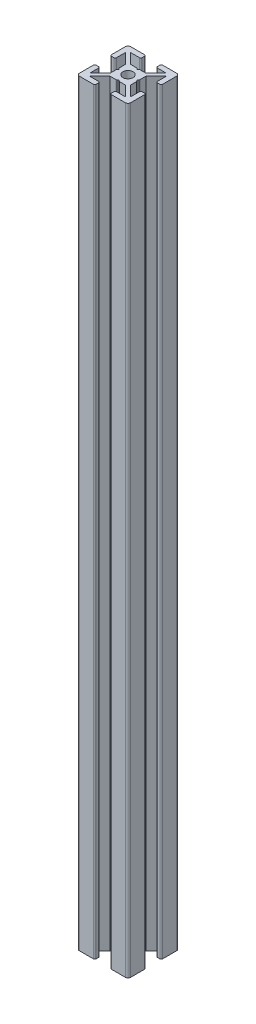
from build123d import *

# Parameters (mm, degrees)
SKETCH1_R           = 2
BOSS_EXTRUDE1_DEPTH = 296
FILLET1_R           = 1
FILLET2_R           = 0.5
FILLET4_R           = 0.5


with BuildPart() as part:
    # Sketch1 → Boss-Extrude1 (new body)
    with BuildSketch(Plane(origin=(0, 0, 0), x_dir=(1, 0, 0), z_dir=(0, 1, 0))):
        Polygon((7, 18), (7, 20), (0, 20), (0, 13), (2, 13), (2, 17), (6, 13), (6, 10.5), (6.5, 10), (6, 9.5), (6, 7), (2, 3), (2, 7), (0, 7), (0, 0), (7, 0), (7, 2), (3, 2), (7, 6), (9.5, 6), (10, 6.5), (10.5, 6), (13, 6), (17, 2), (13, 2), (13, 0), (20, 0), (20, 7), (18, 7), (18, 3), (14, 7), (14, 9.5), (13.5, 10), (14, 10.5), (14, 13), (18, 17), (18, 13), (20, 13), (20, 20), (13, 20), (13, 18), (17, 18), (13, 14), (10.5, 14), (10, 13.5), (9.5, 14), (7, 14), (3, 18), align=None)
        with Locations((10, 10)):
            Circle(SKETCH1_R, mode=Mode.SUBTRACT)
    extrude(amount=BOSS_EXTRUDE1_DEPTH)

    # Fillet1
    fillet1_edges = [part.edges().sort_by_distance(p)[0] for p in [
        (0, 148, -20),
        (20, 148, -20),
        (20, 148, 0),
        (0, 148, 0),
    ]]
    fillet(fillet1_edges, radius=FILLET1_R)

    # Fillet2
    fillet2_edges = [part.edges().sort_by_distance(p)[0] for p in [
        (2, 148, -13),
        (0, 148, -13),
        (7, 148, -20),
        (7, 148, -18),
        (13, 148, -18),
        (13, 148, -20),
        (20, 148, -13),
        (18, 148, -13),
        (18, 148, -7),
        (20, 148, -7),
        (13, 148, 0),
        (13, 148, -2),
        (7, 148, -2),
        (7, 148, 0),
        (0, 148, -7),
        (2, 148, -7),
    ]]
    fillet(fillet2_edges, radius=FILLET2_R)

    # Fillet4
    fillet4_edges = [part.edges().sort_by_distance(p)[0] for p in [
        (9.5, 148, -14),
        (10.5, 148, -14),
        (14, 148, -10.5),
        (14, 148, -9.5),
        (10.5, 148, -6),
        (9.5, 148, -6),
        (6, 148, -9.5),
        (6, 148, -10.5),
    ]]
    fillet(fillet4_edges, radius=FILLET4_R)


solid = part.part
